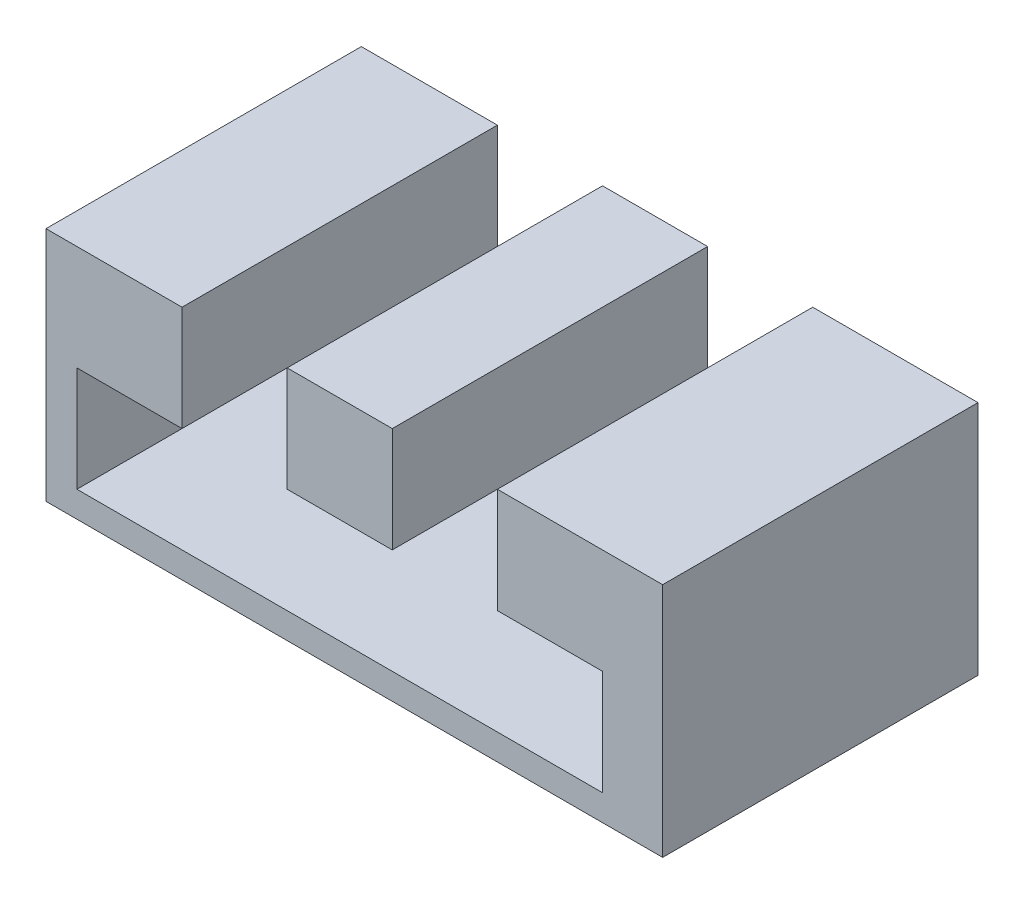
from build123d import *

# Parameters (mm, degrees)
SKETCH3_W           = 58.664947722
SKETCH3_H           = 22.471826884
BOSS_EXTRUDE2_DEPTH = 30
CUT_EXTRUDE1_DEPTH  = 31


with BuildPart() as part:
    # Sketch3 → Boss-Extrude2 (new body)
    with BuildSketch(Plane.XY):
        with Locations((26.389266792, 8.764086558)):
            Rectangle(SKETCH3_W, SKETCH3_H)
    extrude(amount=BOSS_EXTRUDE2_DEPTH)

    # Sketch2 → Cut-Extrude1 (cut, through all)
    with BuildSketch(Plane.XY):
        Polygon((0, 0), (50, 0), (50, 10), (40, 10), (40, 20), (30, 20), (30, 10), (20, 10), (20, 20), (10, 20), (10, 10), (0, 10), align=None)
    extrude(amount=CUT_EXTRUDE1_DEPTH, mode=Mode.SUBTRACT)


solid = part.part
